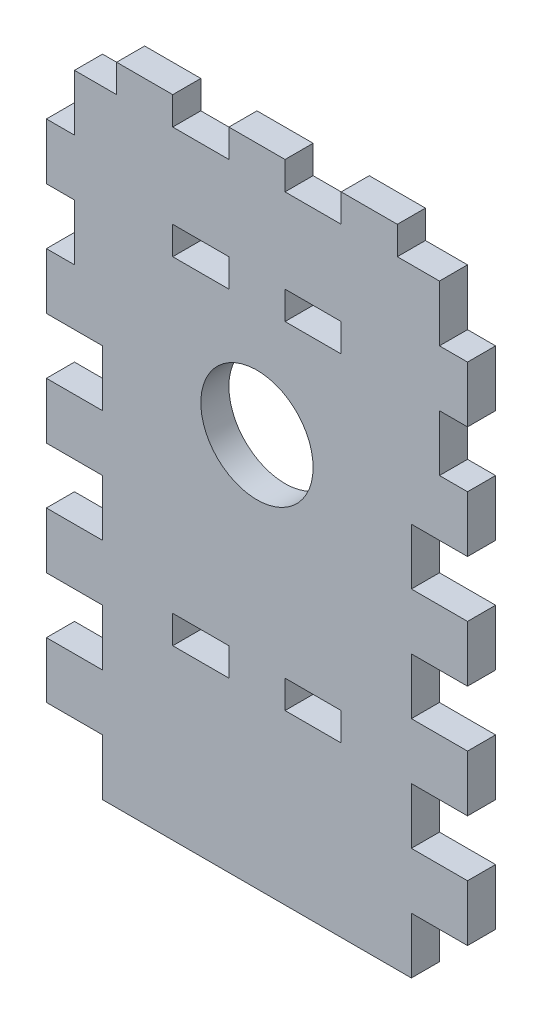
from build123d import *

# Parameters (mm, degrees)
SKETCH1_W           = 95.25
SKETCH1_H           = 177.8
BOSS_EXTRUDE1_DEPTH = 6.35
SKETCH2_W           = 12.7
SKETCH2_H           = 12.7
CUT_EXTRUDE1_DEPTH  = 7.35
LPATTERN1_COUNT     = 4
LPATTERN1_PITCH     = 25.4
SKETCH3_W           = 12.7
SKETCH3_H           = 6.35
CUT_EXTRUDE2_DEPTH  = 7.35
SKETCH5_W           = 6.35
SKETCH5_H           = 12.7
CUT_EXTRUDE4_DEPTH  = 7.35
LPATTERN2_COUNT     = 4
LPATTERN2_PITCH     = 25.4
SKETCH6_W           = 95.25
SKETCH6_H           = 38.1
CUT_EXTRUDE5_DEPTH  = 7.35
SKETCH7_W           = 12.7
SKETCH7_H           = 6.35
BOSS_EXTRUDE2_DEPTH = 6.35
LPATTERN3_COUNT     = 2
LPATTERN3_PITCH     = 25.4
LPATTERN3_COL_COUNT = 2
LPATTERN3_COL_PITCH = 25.4
LPATTERN4_COUNT     = 2
LPATTERN4_PITCH     = 76.2
SKETCH8_R           = 12.7
CUT_EXTRUDE6_DEPTH  = 7.35


with BuildPart() as part:
    # Sketch1 → Boss-Extrude1 (new body)
    with BuildSketch(Plane.XY):
        with Locations((47.625, 88.9)):
            Rectangle(SKETCH1_W, SKETCH1_H)
    extrude(amount=BOSS_EXTRUDE1_DEPTH)

    # Sketch2 → Cut-Extrude1 (cut, through all)
    with BuildSketch(Plane.XY.offset(6.35)):
        with Locations((6.35, 6.35)):
            Rectangle(SKETCH2_W, SKETCH2_H)
        with Locations((88.9, 6.35)):
            Rectangle(SKETCH2_W, SKETCH2_H)
    cut_extrude1 = extrude(amount=-CUT_EXTRUDE1_DEPTH, mode=Mode.SUBTRACT)

    # LPattern1: Cut-Extrude1 ×4
    with Locations(*[(0, i * LPATTERN1_PITCH, 0) for i in range(1, LPATTERN1_COUNT)]):
        add(cut_extrude1, mode=Mode.SUBTRACT)

    # Sketch3 → Cut-Extrude2 (cut, through all)
    with BuildSketch(Plane.XY.offset(6.35)):
        with Locations((34.925, 41.275)):
            Rectangle(SKETCH3_W, SKETCH3_H)
        with Locations((60.325, 41.275)):
            Rectangle(SKETCH3_W, SKETCH3_H)
    cut_extrude2 = extrude(amount=-CUT_EXTRUDE2_DEPTH, mode=Mode.SUBTRACT)

    # Sketch5 → Cut-Extrude4 (cut, through all)
    with BuildSketch(Plane.XY.offset(6.35)):
        with Locations((3.175, 107.95)):
            Rectangle(SKETCH5_W, SKETCH5_H)
        with Locations((92.075, 107.95)):
            Rectangle(SKETCH5_W, SKETCH5_H)
    cut_extrude4 = extrude(amount=-CUT_EXTRUDE4_DEPTH, mode=Mode.SUBTRACT)

    # LPattern2: Cut-Extrude4 ×4
    with Locations(*[(0, i * LPATTERN2_PITCH, 0) for i in range(1, LPATTERN2_COUNT)]):
        add(cut_extrude4, mode=Mode.SUBTRACT)

    # Sketch6 → Cut-Extrude5 (cut, through all)
    with BuildSketch(Plane.XY.offset(6.35)):
        with Locations((47.625, 158.75)):
            Rectangle(SKETCH6_W, SKETCH6_H)
    extrude(amount=-CUT_EXTRUDE5_DEPTH, mode=Mode.SUBTRACT)

    # Sketch7 → Boss-Extrude2 (add)
    with BuildSketch(Plane(origin=(0, 139.7, 0), x_dir=(1, 0, 0), z_dir=(0, 1, 0))):
        with Locations((47.625, -3.175)):
            Rectangle(SKETCH7_W, SKETCH7_H)
    boss_extrude2 = extrude(amount=BOSS_EXTRUDE2_DEPTH)

    # LPattern3: Boss-Extrude2 ×2
    with Locations(*[(i * LPATTERN3_PITCH, 0, 0) for i in range(1, LPATTERN3_COUNT)]):
        add(boss_extrude2)

    # LPattern3 col: Boss-Extrude2 ×2
    with Locations(*[(-i * LPATTERN3_COL_PITCH, 0, 0) for i in range(1, LPATTERN3_COL_COUNT)]):
        add(boss_extrude2)

    # LPattern4: Cut-Extrude2 ×2
    with Locations(*[(0, i * LPATTERN4_PITCH, 0) for i in range(1, LPATTERN4_COUNT)]):
        add(cut_extrude2, mode=Mode.SUBTRACT)

    # Sketch8 → Cut-Extrude6 (cut, through all)
    with BuildSketch(Plane.XY.offset(6.35)):
        with Locations((47.625, 88.9)):
            Circle(SKETCH8_R)
    extrude(amount=-CUT_EXTRUDE6_DEPTH, mode=Mode.SUBTRACT)


solid = part.part
